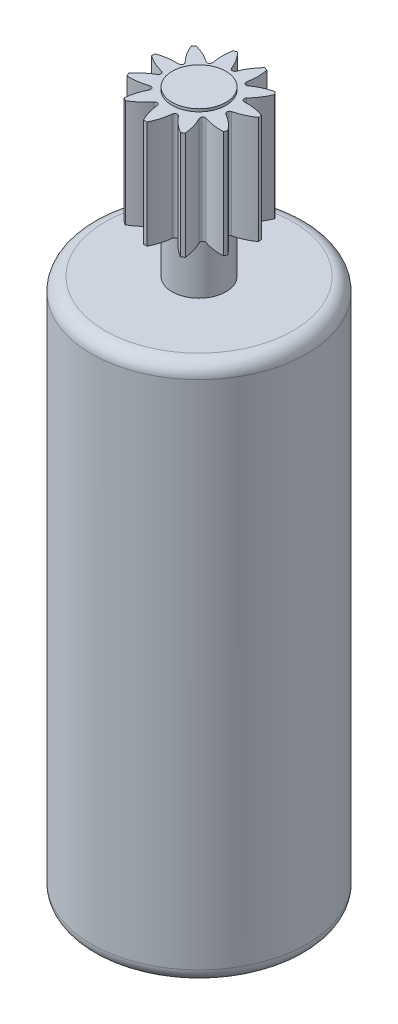
from build123d import *

# Parameters (mm, degrees)
FILLET1_R          = 0.5
CUT_EXTRUDE1_DEPTH = 4
CIRPATTERN1_COUNT  = 11


with BuildPart() as part:
    # Sketch3 → Revolve1 (revolve)
    with BuildSketch(Plane.XY):
        Polygon((0, 0), (0, 26.1), (1, 26.1), (1, 26), (2, 26), (2, 22), (1, 22), (1, 20), (4, 20), (4, 0), align=None)
    revolve(axis=Axis((0, 0, 0), (0, 1, 0)))

    # Fillet1
    fillet1_edges = [part.edges().sort_by_distance(p)[0] for p in [
        (-4, 20, 0),
        (-4, 0, 0),
    ]]
    fillet(fillet1_edges, radius=FILLET1_R)

    # Sketch4 → Cut-Extrude1 (cut)
    with BuildSketch(Plane(origin=(0, 26, 0), x_dir=(1, 0, 0), z_dir=(0, 1, 0))):
        with BuildLine():
            ThreePointArc((-0.5, 1.936491673), (-0.266119458, 1.637619869), (-0.092905413, 1.299949383))
            ThreePointArc((-0.092905413, 1.299949383), (0, 1.236943764), (0.092905413, 1.299949383))
            ThreePointArc((0.092905413, 1.299949383), (0.266119458, 1.637619869), (0.5, 1.936491673))
            ThreePointArc((0.5, 1.936491673), (0, 2), (-0.5, 1.936491673))
        make_face()
    cut_extrude1 = extrude(amount=-CUT_EXTRUDE1_DEPTH, mode=Mode.SUBTRACT)

    # CirPattern1: Cut-Extrude1 ×11 about axis
    cirpattern1_axis = Axis((0, 0, 0), (0, 1, 0))
    for i in range(1, CIRPATTERN1_COUNT):
        add(cut_extrude1.rotate(cirpattern1_axis, i * 360 / CIRPATTERN1_COUNT), mode=Mode.SUBTRACT)


solid = part.part
